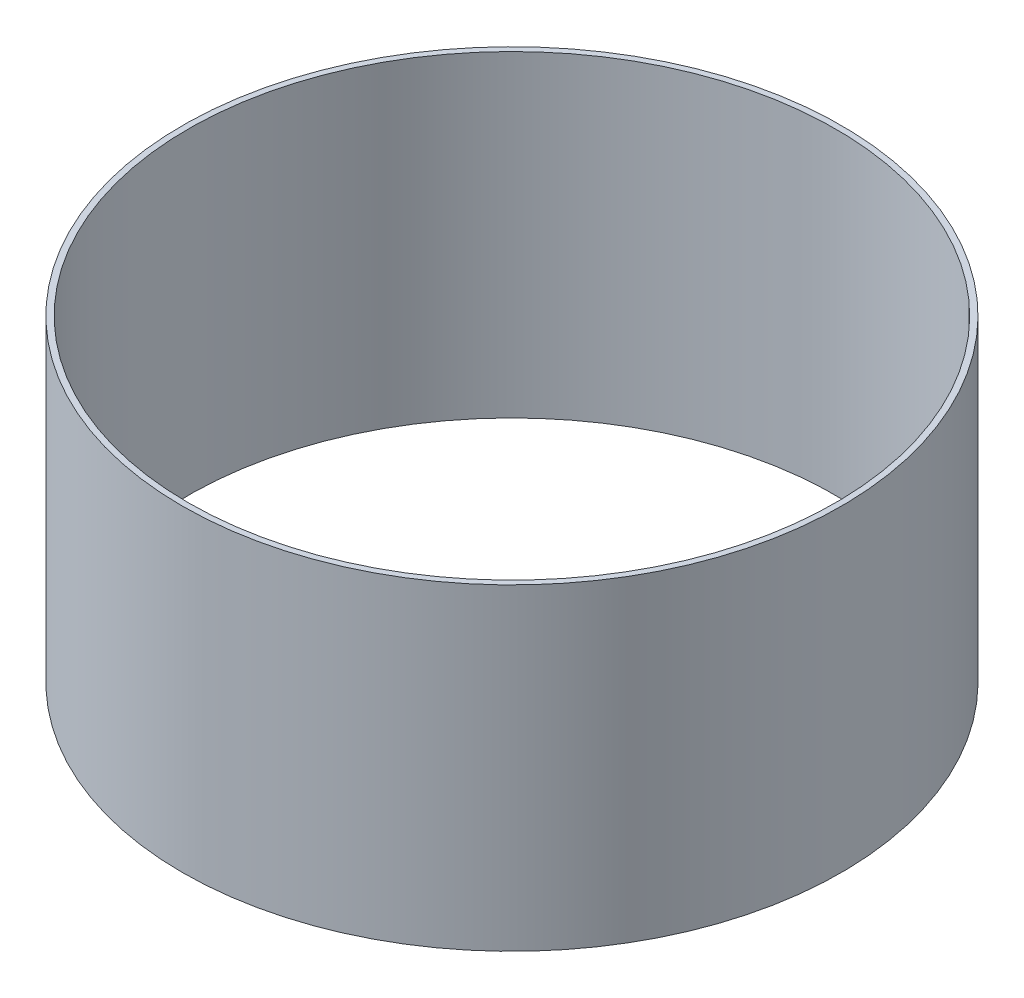
from build123d import *

# Parameters (mm, degrees)
SKETCH1_R           = 77.58
SKETCH1_R_2         = 76.2
BOSS_EXTRUDE1_DEPTH = 74.7


with BuildPart() as part:
    # Sketch1 → Boss-Extrude1 (new body)
    with BuildSketch(Plane(origin=(0, 0, 0), x_dir=(1, 0, 0), z_dir=(0, 1, 0))):
        Circle(SKETCH1_R)
        Circle(SKETCH1_R_2, mode=Mode.SUBTRACT)
    extrude(amount=BOSS_EXTRUDE1_DEPTH)


solid = part.part
